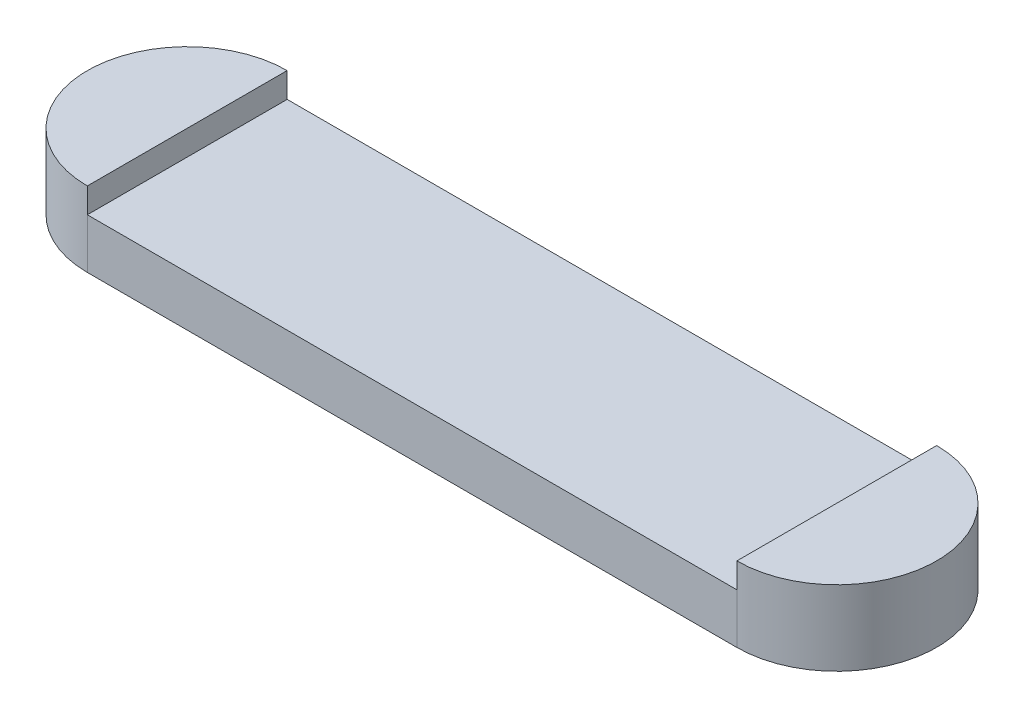
from build123d import *

# Parameters (mm, degrees)
BOSS_EXTRUDE1_DEPTH = 2
BOSS_EXTRUDE2_DEPTH = 1


with BuildPart() as part:
    # Sketch1 → Boss-Extrude1 (new body)
    with BuildSketch(Plane(origin=(0, 0, 0), x_dir=(1, 0, 0), z_dir=(0, 1, 0))):
        with BuildLine():
            Line((0, -4), (-26, -4))
            ThreePointArc((-26, -4), (-30, 0), (-26, 4))
            Line((-26, 4), (0, 4))
            ThreePointArc((0, 4), (4, 0), (0, -4))
        make_face()
    extrude(amount=BOSS_EXTRUDE1_DEPTH)

    # Sketch2 → Boss-Extrude2 (add)
    with BuildSketch(Plane(origin=(0, 2, 0), x_dir=(1, 0, 0), z_dir=(0, 1, 0))):
        with BuildLine():
            Line((-26, 4), (-26, -4))
            ThreePointArc((-26, -4), (-28.828427125, -2.828427125), (-30, 0))
            ThreePointArc((-30, 0), (-28.828427125, 2.828427125), (-26, 4))
        make_face()
        with BuildLine():
            Line((0, 4), (0, -4))
            ThreePointArc((0, -4), (4, 0), (0, 4))
        make_face()
    extrude(amount=BOSS_EXTRUDE2_DEPTH)


solid = part.part
